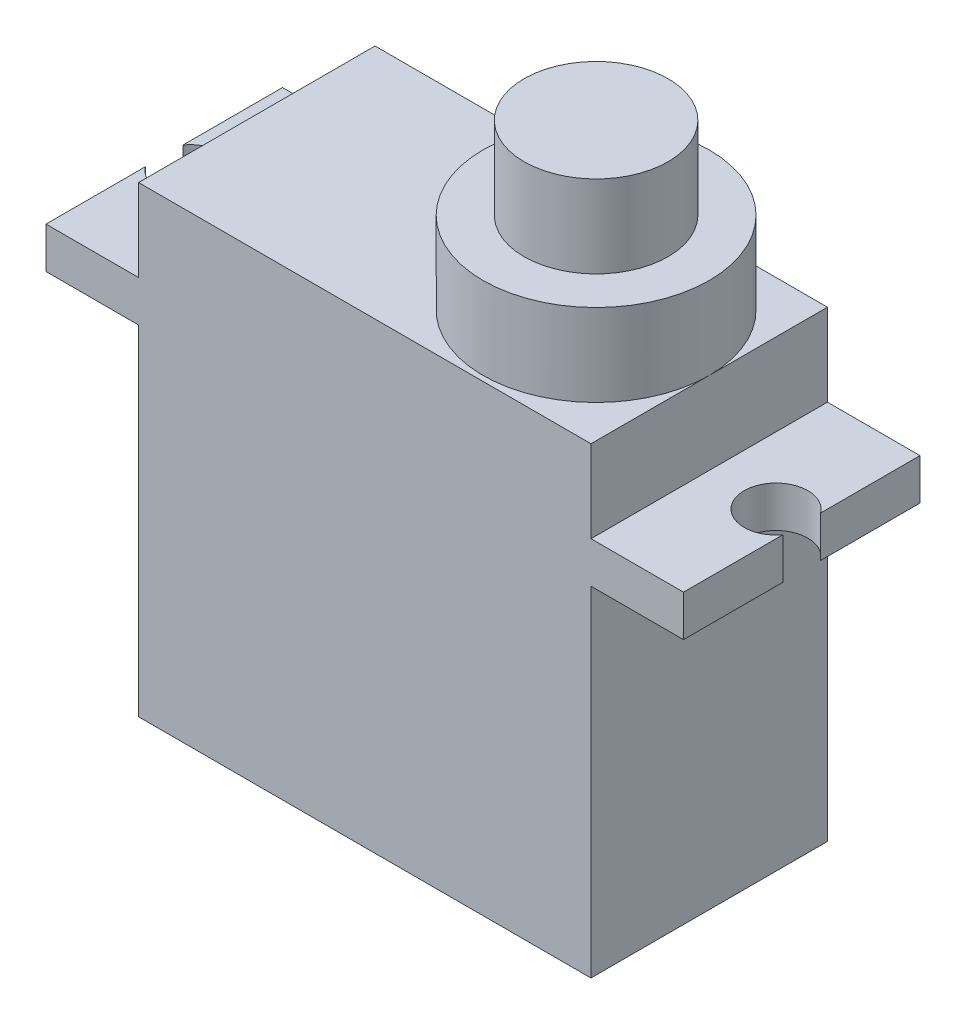
from build123d import *

# Parameters (mm, degrees)
SKETCH1_W           = 22
SKETCH1_H           = 11.5
BOSS_EXTRUDE1_DEPTH = 16.5
BOSS_EXTRUDE2_DEPTH = 2
SKETCH4_W           = 22
SKETCH4_H           = 11.5
BOSS_EXTRUDE3_DEPTH = 4
SKETCH5_R           = 5.5
BOSS_EXTRUDE4_DEPTH = 4
SKETCH7_R           = 3.5
BOSS_EXTRUDE5_DEPTH = 4


with BuildPart() as part:
    # Sketch1 → Boss-Extrude1 (new body)
    with BuildSketch(Plane(origin=(0, 0, 0), x_dir=(1, 0, 0), z_dir=(0, 1, 0))):
        Rectangle(SKETCH1_W, SKETCH1_H)
    extrude(amount=BOSS_EXTRUDE1_DEPTH)

    # Sketch2 → Boss-Extrude2 (add)
    with BuildSketch(Plane(origin=(0, 16.5, 0), x_dir=(1, 0, 0), z_dir=(0, 1, 0))):
        with BuildLine():
            Line((-15.5, 5.75), (15.5, 5.75))
            Line((15.5, 5.75), (15.5, 0.916515139))
            ThreePointArc((15.5, 0.916515139), (12.7, 0), (15.5, -0.916515139))
            Line((15.5, -0.916515139), (15.5, -5.75))
            Line((15.5, -5.75), (-15.5, -5.75))
            Line((-15.5, -5.75), (-15.5, -0.916515139))
            ThreePointArc((-15.5, -0.916515139), (-12.7, 0), (-15.5, 0.916515139))
            Line((-15.5, 0.916515139), (-15.5, 5.75))
        make_face()
    extrude(amount=BOSS_EXTRUDE2_DEPTH)

    # Sketch4 → Boss-Extrude3 (add)
    with BuildSketch(Plane(origin=(0, 18.5, 0), x_dir=(1, 0, 0), z_dir=(0, 1, 0))):
        Rectangle(SKETCH4_W, SKETCH4_H)
    extrude(amount=BOSS_EXTRUDE3_DEPTH)

    # Sketch5 → Boss-Extrude4 (add)
    with BuildSketch(Plane(origin=(0, 22.5, 0), x_dir=(1, 0, 0), z_dir=(0, 1, 0))):
        with Locations((5.5, 0)):
            Circle(SKETCH5_R)
    extrude(amount=BOSS_EXTRUDE4_DEPTH)

    # Sketch7 → Boss-Extrude5 (add)
    with BuildSketch(Plane(origin=(0, 26.5, 0), x_dir=(1, 0, 0), z_dir=(0, 1, 0))):
        with Locations((5.5, 0)):
            Circle(SKETCH7_R)
    extrude(amount=BOSS_EXTRUDE5_DEPTH)


solid = part.part
